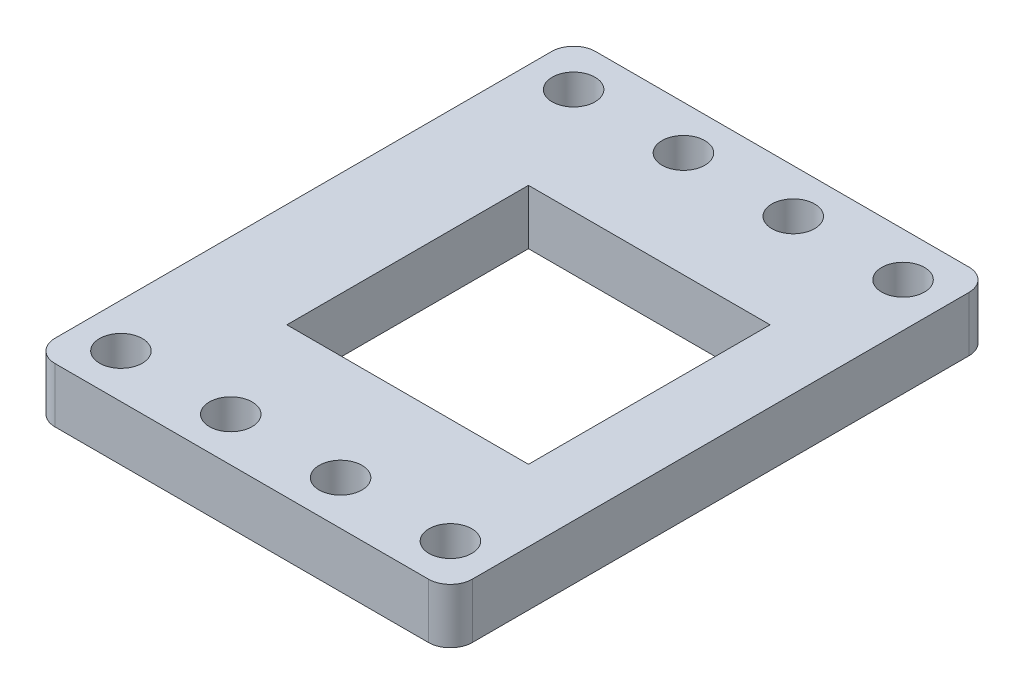
from build123d import *

# Parameters (mm, degrees)
BOSS_EXTRUDE1_DEPTH = 5
SKETCH2_R           = 1.95
SKETCH2_W           = 22
SKETCH2_H           = 22
CUT_EXTRUDE1_DEPTH  = 6


with BuildPart() as part:
    # Sketch1 → Boss-Extrude1 (new body)
    with BuildSketch(Plane(origin=(0, 0, 0), x_dir=(1, 0, 0), z_dir=(0, 1, 0))):
        with BuildLine():
            Line((-36, 0), (-2, 0))
            ThreePointArc((-2, 0), (-0.585786438, -0.585786438), (0, -2))
            Line((0, -2), (0, -47.22))
            ThreePointArc((0, -47.22), (-0.585786438, -48.634213562), (-2, -49.22))
            Line((-2, -49.22), (-36, -49.22))
            ThreePointArc((-36, -49.22), (-37.414213562, -48.634213562), (-38, -47.22))
            Line((-38, -47.22), (-38, -2))
            ThreePointArc((-38, -2), (-37.414213562, -0.585786438), (-36, 0))
        make_face()
    extrude(amount=BOSS_EXTRUDE1_DEPTH)

    # Sketch2 → Cut-Extrude1 (cut, through all)
    with BuildSketch(Plane(origin=(0, 5, 0), x_dir=(1, 0, 0), z_dir=(0, 1, 0))):
        with Locations((-4, -4)):
            Circle(SKETCH2_R)
        with Locations((-14, -4)):
            Circle(SKETCH2_R)
        with Locations((-24, -4)):
            Circle(SKETCH2_R)
        with Locations((-54, -4)):
            Circle(SKETCH2_R)
        with Locations((-34, -4)):
            Circle(SKETCH2_R)
        with Locations((-44, -4)):
            Circle(SKETCH2_R)
        with Locations((-44, -45.22)):
            Circle(SKETCH2_R)
        with Locations((-34, -45.22)):
            Circle(SKETCH2_R)
        with Locations((-54, -45.22)):
            Circle(SKETCH2_R)
        with Locations((-24, -45.22)):
            Circle(SKETCH2_R)
        with Locations((-14, -45.22)):
            Circle(SKETCH2_R)
        with Locations((-4, -45.22)):
            Circle(SKETCH2_R)
        with Locations((-17.5, -24.61)):
            Rectangle(SKETCH2_W, SKETCH2_H)
    extrude(amount=-CUT_EXTRUDE1_DEPTH, mode=Mode.SUBTRACT)


solid = part.part
